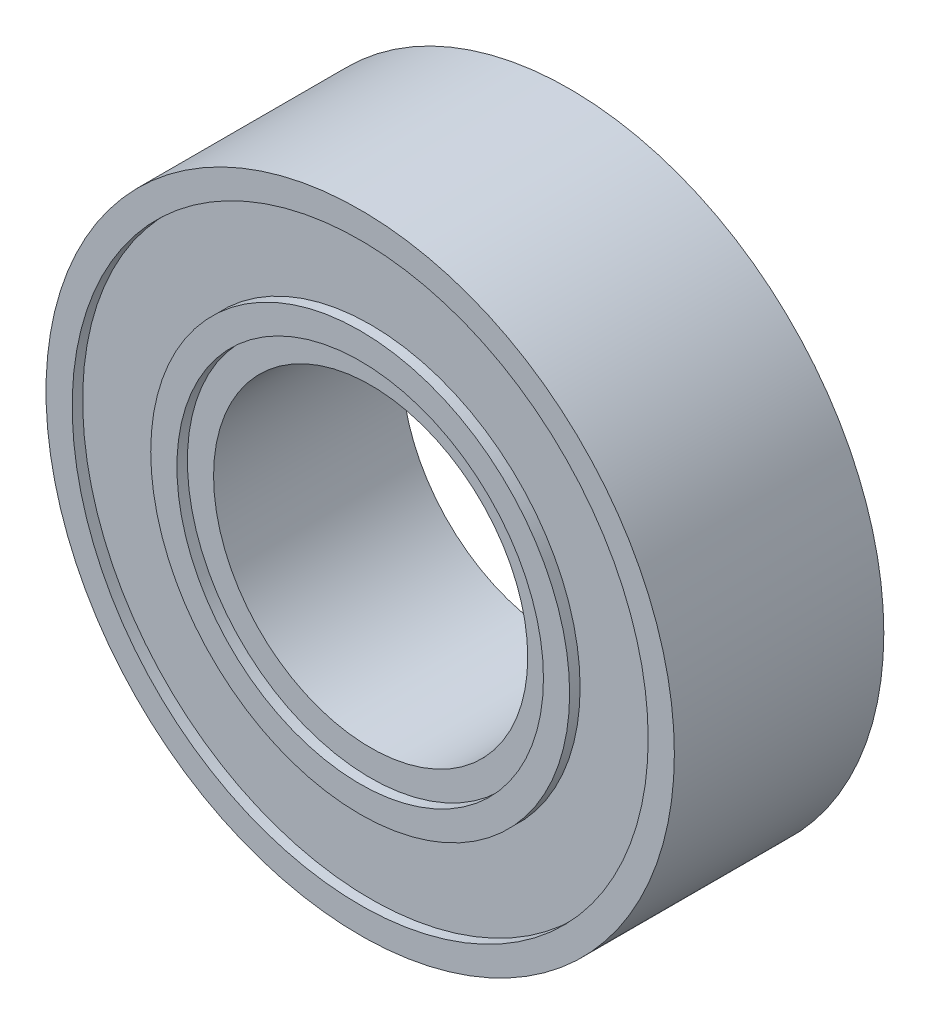
from build123d import *

# Parameters (mm, degrees)
SKETCH_1_W          = 3
SKETCH_1_H          = 4
SKETCH_2_R          = 3.5
CUT_EXTRUDE_1_DEPTH = 0.2
SKETCH_3_R          = 5.5
SKETCH_3_R_2        = 4
CUT_EXTRUDE_2_DEPTH = 0.2


with BuildPart() as part:
    # Эскиз1 → Повернуть1 (revolve)
    with BuildSketch(Plane(origin=(0, 0, 0), x_dir=(1, 0, 0), z_dir=(0, 1, 0))):
        with Locations((-4.5, 2)):
            Rectangle(SKETCH_1_W, SKETCH_1_H)
    revolve(axis=Axis((0, 0, 0), (0, 0, -1)))

    # Эскиз2 → Вырез-Вытянуть1 (cut)
    with BuildSketch(Plane.XY):
        Circle(SKETCH_2_R)
    cut_extrude_1 = extrude(amount=-CUT_EXTRUDE_1_DEPTH, mode=Mode.SUBTRACT)

    # Эскиз3 → Вырез-Вытянуть2 (cut)
    with BuildSketch(Plane.XY):
        Circle(SKETCH_3_R)
        Circle(SKETCH_3_R_2, mode=Mode.SUBTRACT)
    cut_extrude_2 = extrude(amount=-CUT_EXTRUDE_2_DEPTH, mode=Mode.SUBTRACT)

    # Зеркальное отражение1: Вырез-Вытянуть1, Вырез-Вытянуть2 across plane
    add(cut_extrude_1.mirror(Plane.XY.offset(-2)), mode=Mode.SUBTRACT)
    add(cut_extrude_2.mirror(Plane.XY.offset(-2)), mode=Mode.SUBTRACT)


solid = part.part
